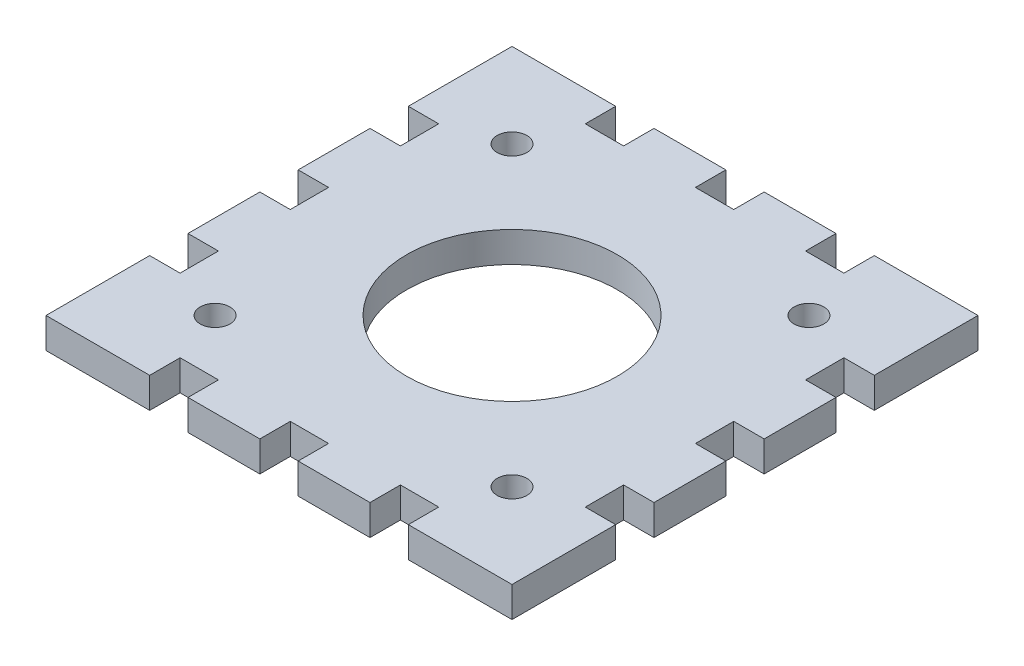
from build123d import *

# Parameters (mm, degrees)
SKETCH2_R           = 1.55
SKETCH2_R_2         = 11
BOSS_EXTRUDE1_DEPTH = 3.175


with BuildPart() as part:
    # Sketch2 → Boss-Extrude1 (new body)
    with BuildSketch(Plane(origin=(0, 0, 0), x_dir=(1, 0, 0), z_dir=(0, 1, 0))):
        Polygon((24.325, 2), (24.325, 9.5), (21.15, 9.5), (21.15, 13.5), (24.325, 13.5), (24.325, 24.325), (13.5, 24.325), (13.5, 21.15), (9.5, 21.15), (9.5, 24.325), (2, 24.325), (2, 21.15), (-2, 21.15), (-2, 24.325), (-9.5, 24.325), (-9.5, 21.15), (-13.5, 21.15), (-13.5, 24.325), (-24.325, 24.325), (-24.325, 13.5), (-21.15, 13.5), (-21.15, 9.5), (-24.325, 9.5), (-24.325, 2), (-21.15, 2), (-21.15, -2), (-24.325, -2), (-24.325, -9.5), (-21.15, -9.5), (-21.15, -13.5), (-24.325, -13.5), (-24.325, -24.325), (-13.5, -24.325), (-13.5, -21.15), (-9.5, -21.15), (-9.5, -24.325), (-2, -24.325), (-2, -21.15), (2, -21.15), (2, -24.325), (9.5, -24.325), (9.5, -21.15), (13.5, -21.15), (13.5, -24.325), (24.325, -24.325), (24.325, -13.5), (21.15, -13.5), (21.15, -9.5), (24.325, -9.5), (24.325, -2), (21.15, -2), (21.15, 2), align=None)
        with Locations((-15.5, -15.5)):
            Circle(SKETCH2_R, mode=Mode.SUBTRACT)
        with Locations((15.5, -15.5)):
            Circle(SKETCH2_R, mode=Mode.SUBTRACT)
        Circle(SKETCH2_R_2, mode=Mode.SUBTRACT)
        with Locations((-15.5, 15.5)):
            Circle(SKETCH2_R, mode=Mode.SUBTRACT)
        with Locations((15.5, 15.5)):
            Circle(SKETCH2_R, mode=Mode.SUBTRACT)
    extrude(amount=BOSS_EXTRUDE1_DEPTH)


solid = part.part
